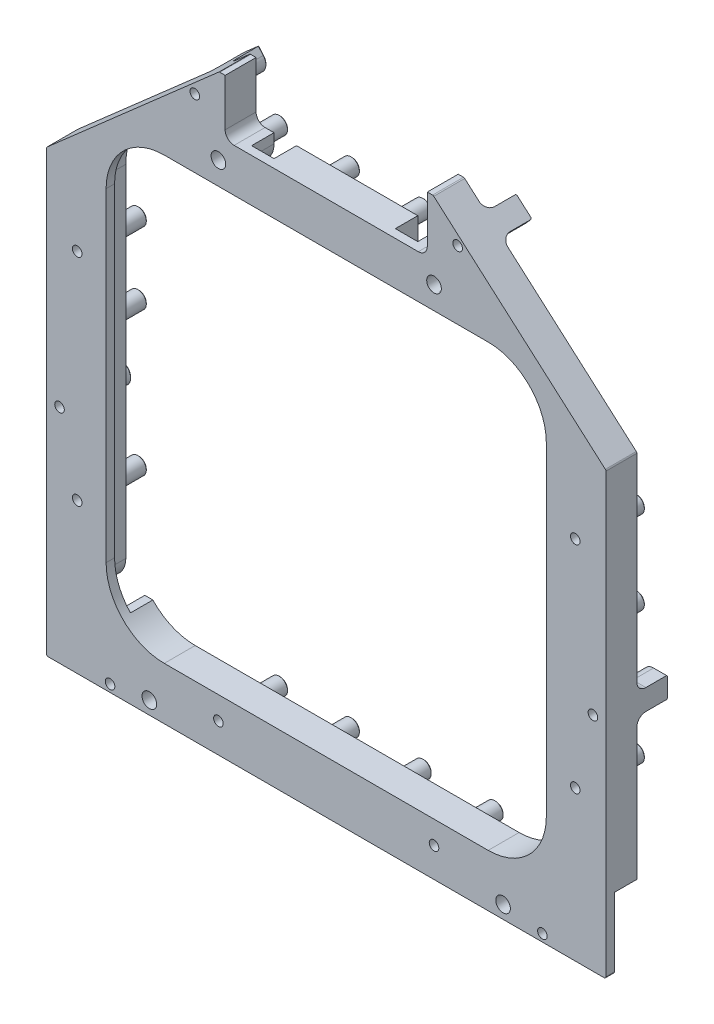
from build123d import *
from OCP.BRepFilletAPI import BRepFilletAPI_MakeChamfer

# Parameters (mm, degrees)
SKETCH1_R                      = 2.38125
BOSS_EXTRUDE1_DEPTH            = 8.6623
BOSS_EXTRUDE1_2_DEPTH          = 8.6623
BOSS_EXTRUDE1_3_DEPTH          = 8.6623
BOSS_EXTRUDE1_4_DEPTH          = 8.6623
BOSS_EXTRUDE1_5_DEPTH          = 8.6623
BOSS_EXTRUDE1_6_DEPTH          = 8.6623
BOSS_EXTRUDE1_7_DEPTH          = 8.6623
BOSS_EXTRUDE1_8_DEPTH          = 8.6623
BOSS_EXTRUDE1_9_DEPTH          = 8.6623
BOSS_EXTRUDE1_10_DEPTH         = 8.6623
BOSS_EXTRUDE1_11_DEPTH         = 8.6623
BOSS_EXTRUDE1_12_DEPTH         = 8.6623
BOSS_EXTRUDE1_13_DEPTH         = 8.6623
BOSS_EXTRUDE1_14_DEPTH         = 8.6623
BOSS_EXTRUDE1_15_DEPTH         = 8.6623
BOSS_EXTRUDE1_16_DEPTH         = 8.6623
BOSS_EXTRUDE1_17_DEPTH         = 8.6623
BOSS_EXTRUDE1_18_DEPTH         = 8.6623
BOSS_EXTRUDE1_19_DEPTH         = 8.6623
BOSS_EXTRUDE1_20_DEPTH         = 8.6623
BOSS_EXTRUDE2_START            = -17.4073
BOSS_EXTRUDE2_DEPTH            = 8.745
SKETCH6_W                      = 57.15
SKETCH6_H                      = 15.875
CUT_EXTRUDE1_DEPTH             = 189.77689907
FILLET1_R                      = 2.54
HOLE1_AT_2_COUNT               = 2
HOLE1_AT_2_PITCH               = 143.341726759
HOLE1_AT_3_COUNT               = 2
HOLE1_AT_3_PITCH               = 60.95999972
HOLE1_AT_4_COUNT               = 2
HOLE1_AT_4_PITCH               = 163.228712511
F_4_CLEARANCE_HOLE1_D          = 3.4544
HOLE2_AT_2_COUNT               = 2
HOLE2_AT_2_PITCH               = 74.316634453
HOLE2_AT_3_COUNT               = 2
HOLE2_AT_3_PITCH               = 103.157062627
HOLE2_AT_4_COUNT               = 2
HOLE2_AT_4_PITCH               = 147.81334761
HOLE2_AT_5_COUNT               = 2
HOLE2_AT_5_PITCH               = 184.754966793
HOLE2_AT_6_COUNT               = 2
HOLE2_AT_6_PITCH               = 158.272291166
HOLE2_AT_7_COUNT               = 2
HOLE2_AT_7_PITCH               = 14.486299694
HOLE2_AT_8_COUNT               = 2
HOLE2_AT_8_PITCH               = 68.849073307
HOLE2_AT_9_COUNT               = 2
HOLE2_AT_9_PITCH               = 120.885266931
HOLE2_AT_10_COUNT              = 2
HOLE2_AT_10_PITCH              = 64.409856661
HOLE2_AT_11_COUNT              = 2
HOLE2_AT_11_PITCH              = 120.791325043
HOLE2_AT_12_COUNT              = 2
HOLE2_AT_12_PITCH              = 158.288225499
HOLE2_AT_13_COUNT              = 2
HOLE2_AT_13_PITCH              = 164.709827419
HOLE2_AT_14_COUNT              = 2
HOLE2_AT_14_PITCH              = 150.329588612
F_2_CLEARANCE_HOLE1_D          = 2.7051
FILLET2_R                      = 2.54
CHAMFER1_SIZE                  = 0.254
CHAMFER1_SIZE2                 = 0.267062899
CUT_EXTRUDE2_DEPTH             = 6.35
CUT_EXTRUDE3_DEPTH             = 6.35
CUT_EXTRUDE3_DIRECTION_2_REACH = 190.777
FILLET3_R                      = 6.35
FILLET3_OF_MIRROR1_R           = 6.35


with BuildPart() as part:
    # Sketch1 → Boss-Extrude1 (new body)
    with BuildSketch(Plane.XY):
        with Locations(Location((10.159982158, 2.8e-08, 0), (0, 0, 270))):
            Circle(SKETCH1_R)
    extrude(amount=BOSS_EXTRUDE1_DEPTH)



with BuildPart() as body_2:
    # Sketch1 → Boss-Extrude1 2 (new body)
    with BuildSketch(Plane.XY):
        with Locations(Location((30.479982158, 2.8e-08, 0), (0, 0, 270))):
            Circle(SKETCH1_R)
    extrude(amount=BOSS_EXTRUDE1_2_DEPTH)


with BuildPart() as body_3:
    # Sketch1 → Boss-Extrude1 3 (new body)
    with BuildSketch(Plane.XY):
        with Locations(Location((50.799982231, 7.8e-08, 0), (0, 0, 270))):
            Circle(SKETCH1_R)
    extrude(amount=BOSS_EXTRUDE1_3_DEPTH)


with BuildPart() as body_4:
    # Sketch1 → Boss-Extrude1 4 (new body)
    with BuildSketch(Plane.XY):
        with Locations(Location((71.119982231, 7.8e-08, 0), (0, 0, 270))):
            Circle(SKETCH1_R)
    extrude(amount=BOSS_EXTRUDE1_4_DEPTH)


with BuildPart() as body_5:
    # Sketch1 → Boss-Extrude1 5 (new body)
    with BuildSketch(Plane.XY):
        with Locations(Location((111.045607114, -42.310549629, 0), (0, 0, 270))):
            Circle(SKETCH1_R)
    extrude(amount=BOSS_EXTRUDE1_5_DEPTH)


with BuildPart() as body_6:
    # Sketch1 → Boss-Extrude1 6 (new body)
    with BuildSketch(Plane.XY):
        with Locations(Location((111.045607114, -65.880549629, 0), (0, 0, 270))):
            Circle(SKETCH1_R)
    extrude(amount=BOSS_EXTRUDE1_6_DEPTH)


with BuildPart() as body_7:
    # Sketch1 → Boss-Extrude1 7 (new body)
    with BuildSketch(Plane.XY):
        with Locations(Location((111.045607114, -103.270549629, 0), (0, 0, 270))):
            Circle(SKETCH1_R)
    extrude(amount=BOSS_EXTRUDE1_7_DEPTH)


with BuildPart() as body_8:
    # Sketch1 → Boss-Extrude1 8 (new body)
    with BuildSketch(Plane.XY):
        with Locations(Location((71.119982231, -137.32609977, 0), (0, 0, 270))):
            Circle(SKETCH1_R)
    extrude(amount=BOSS_EXTRUDE1_8_DEPTH)


with BuildPart() as body_9:
    # Sketch1 → Boss-Extrude1 9 (new body)
    with BuildSketch(Plane.XY):
        with Locations(Location((50.799982231, -137.32609977, 0), (0, 0, 270))):
            Circle(SKETCH1_R)
    extrude(amount=BOSS_EXTRUDE1_9_DEPTH)


with BuildPart() as body_10:
    # Sketch1 → Boss-Extrude1 10 (new body)
    with BuildSketch(Plane.XY):
        with Locations(Location((30.479982158, -137.32609982, 0), (0, 0, 270))):
            Circle(SKETCH1_R)
    extrude(amount=BOSS_EXTRUDE1_10_DEPTH)


with BuildPart() as body_11:
    # Sketch1 → Boss-Extrude1 11 (new body)
    with BuildSketch(Plane.XY):
        with Locations(Location((10.159982158, -137.32609982, 0), (0, 0, 270))):
            Circle(SKETCH1_R)
    extrude(amount=BOSS_EXTRUDE1_11_DEPTH)


with BuildPart() as body_12:
    # Sketch1 → Boss-Extrude1 12 (new body)
    with BuildSketch(Plane.XY):
        with Locations(Location((-29.76564269, -103.270549629, 0), (0, 0, 270))):
            Circle(SKETCH1_R)
    extrude(amount=BOSS_EXTRUDE1_12_DEPTH)


with BuildPart() as body_13:
    # Sketch1 → Boss-Extrude1 13 (new body)
    with BuildSketch(Plane.XY):
        with Locations(Location((-29.76564269, -62.630549629, 0), (0, 0, 270))):
            Circle(SKETCH1_R)
    extrude(amount=BOSS_EXTRUDE1_13_DEPTH)


with BuildPart() as body_14:
    # Sketch1 → Boss-Extrude1 14 (new body)
    with BuildSketch(Plane.XY):
        with Locations(Location((-29.76564269, -42.310549629, 0), (0, 0, 270))):
            Circle(SKETCH1_R)
    extrude(amount=BOSS_EXTRUDE1_14_DEPTH)


with BuildPart() as body_15:
    # Sketch1 → Boss-Extrude1 15 (new body)
    with BuildSketch(Plane.XY):
        with BuildLine():
            Line((-23.418817868, -143.593049925), (-23.418817868, -145.688549927))
            Line((-23.418817868, -145.688549927), (-17.538717866, -145.688549927))
            Line((-17.538717866, -145.688549927), (-17.538717866, -143.593049925))
            ThreePointArc((-17.538717866, -143.593049925), (-20.478767868, -140.652999924), (-23.418817868, -143.593049925))
        make_face()
    extrude(amount=BOSS_EXTRUDE1_15_DEPTH)


with BuildPart() as body_16:
    # Sketch1 → Boss-Extrude1 16 (new body)
    with BuildSketch(Plane.XY):
        with BuildLine():
            Line((98.818682132, -143.593049842), (98.818682132, -145.688549927))
            Line((98.818682132, -145.688549927), (104.698782134, -145.688549927))
            Line((104.698782134, -145.688549927), (104.698782134, -143.593049842))
            ThreePointArc((104.698782134, -143.593049842), (101.758732132, -140.652999841), (98.818682132, -143.593049842))
        make_face()
    extrude(amount=BOSS_EXTRUDE1_16_DEPTH)


with BuildPart() as body_17:
    # Sketch1 → Boss-Extrude1 17 (new body)
    with BuildSketch(Plane.XY):
        with BuildLine():
            Line((116.04306139, -85.890599647), (119.729232093, -85.890599647))
            Line((119.729232093, -85.890599647), (119.729232093, -80.010499645))
            Line((119.729232093, -80.010499645), (116.04306139, -80.010499645))
            ThreePointArc((116.04306139, -80.010499645), (113.103011388, -82.950549647), (116.04306139, -85.890599647))
        make_face()
    extrude(amount=BOSS_EXTRUDE1_17_DEPTH)


with BuildPart() as body_18:
    # Sketch1 → Boss-Extrude1 18 (new body)
    with BuildSketch(Plane.XY):
        with BuildLine():
            Line((80.007688365, 10.915360266), (81.390206518, 12.490086848))
            Line((81.390206518, 12.490086848), (76.971428292, 16.369516574))
            Line((76.971428292, 16.369516574), (75.588910139, 14.794789992))
            ThreePointArc((75.588910139, 14.794789992), (75.858584389, 10.645686016), (80.007688365, 10.915360266))
        make_face()
    extrude(amount=BOSS_EXTRUDE1_18_DEPTH)


with BuildPart() as body_19:
    # Sketch1 → Boss-Extrude1 19 (new body)
    with BuildSketch(Plane.XY):
        with BuildLine():
            Line((5.69105391, 14.794789945), (4.308535755, 16.369516525))
            Line((4.308535755, 16.369516525), (-0.110242466, 12.490086792))
            Line((-0.110242466, 12.490086792), (1.272275689, 10.915360213))
            ThreePointArc((1.272275689, 10.915360213), (5.421379666, 10.645685968), (5.69105391, 14.794789945))
        make_face()
    extrude(amount=BOSS_EXTRUDE1_19_DEPTH)


with BuildPart() as body_20:
    # Sketch1 → Boss-Extrude1 20 (new body)
    with BuildSketch(Plane.XY):
        with BuildLine():
            Line((-34.763097208, -80.01049975), (-38.449267911, -80.01049975))
            Line((-38.449267911, -80.01049975), (-38.449267911, -85.890599752))
            Line((-38.449267911, -85.890599752), (-34.763097208, -85.890599752))
            ThreePointArc((-34.763097208, -85.890599752), (-31.823047205, -82.95054975), (-34.763097208, -80.01049975))
        make_face()
    extrude(amount=BOSS_EXTRUDE1_20_DEPTH)


with BuildPart() as part_1:
    add(part.part)

    add(body_2.part)  # Boss-Extrude2 merges body 2

    add(body_3.part)  # Boss-Extrude2 merges body 3

    add(body_4.part)  # Boss-Extrude2 merges body 4

    add(body_5.part)  # Boss-Extrude2 merges body 5

    add(body_6.part)  # Boss-Extrude2 merges body 6

    add(body_7.part)  # Boss-Extrude2 merges body 7

    add(body_8.part)  # Boss-Extrude2 merges body 8

    add(body_9.part)  # Boss-Extrude2 merges body 9

    add(body_10.part)  # Boss-Extrude2 merges body 10

    add(body_11.part)  # Boss-Extrude2 merges body 11

    add(body_12.part)  # Boss-Extrude2 merges body 12

    add(body_13.part)  # Boss-Extrude2 merges body 13

    add(body_14.part)  # Boss-Extrude2 merges body 14

    add(body_15.part)  # Boss-Extrude2 merges body 15

    add(body_16.part)  # Boss-Extrude2 merges body 16

    add(body_17.part)  # Boss-Extrude2 merges body 17

    add(body_18.part)  # Boss-Extrude2 merges body 18

    add(body_19.part)  # Boss-Extrude2 merges body 19

    add(body_20.part)  # Boss-Extrude2 merges body 20
    # Sketch3 → Boss-Extrude2 (add)
    with BuildSketch(Plane(origin=(0, 0, 0), x_dir=(-1, 0, 0), z_dir=(0, 0, -1)).offset(BOSS_EXTRUDE2_START)):
        with BuildLine():
            Line((-71.046564052, 21.571202036), (-119.556387965, -21.017595879))
            ThreePointArc((-119.556387965, -21.017595879), (-119.684008024, -21.189818788), (-119.729232049, -21.399347777))
            Line((-119.729232049, -21.399347777), (-119.729232049, -145.18054983))
            ThreePointArc((-119.729232049, -145.18054983), (-119.580442319, -145.539760015), (-119.221232133, -145.68854983))
            Line((-119.221232133, -145.68854983), (37.941267867, -145.68854983))
            ThreePointArc((37.941267867, -145.68854983), (38.300478036, -145.539760106), (38.449267867, -145.180549937))
            Line((38.449267867, -145.180549937), (38.449267867, -21.399347884))
            ThreePointArc((38.449267867, -21.399347884), (38.404043849, -21.18981893), (38.276423867, -21.017595986))
            Line((38.276423867, -21.017595986), (-10.233399988, 21.571201994))
            ThreePointArc((-10.233399988, 21.571201994), (-10.389483243, 21.664841495), (-10.568555904, 21.697450096))
            Line((-10.568555904, 21.697450096), (-24.76498202, 21.697450096))
            Line((-24.76498202, 21.697450096), (-24.76498202, 8.997450096))
            ThreePointArc((-24.76498202, 8.997450096), (-25.69491799, 6.752386066), (-27.93998202, 5.822450096))
            Line((-27.93998202, 5.822450096), (-53.33998202, 5.822450096))
            ThreePointArc((-53.33998202, 5.822450096), (-55.58504605, 6.752386066), (-56.51498202, 8.997450096))
            Line((-56.51498202, 8.997450096), (-56.51498202, 21.697450096))
            Line((-56.51498202, 21.697450096), (-70.711408136, 21.697450096))
            ThreePointArc((-70.711408136, 21.697450096), (-70.890480782, 21.664841498), (-71.046564052, 21.571202036))
        make_face()
        with BuildLine():
            Line((-102.86998205, -22.874190224), (-102.86998205, -114.451909481))
            ThreePointArc((-102.86998205, -114.451909481), (-98.054483544, -126.077551284), (-86.428841741, -130.893049852))
            Line((-86.428841741, -130.893049852), (5.148877516, -130.893049852))
            ThreePointArc((5.148877516, -130.893049852), (16.774519319, -126.077551346), (21.590017887, -114.451909543))
            Line((21.590017887, -114.451909543), (21.590017887, -22.874190286))
            ThreePointArc((21.590017887, -22.874190286), (16.774519381, -11.248548483), (5.148877578, -6.433049915))
            Line((5.148877578, -6.433049915), (-86.428841679, -6.433049915))
            ThreePointArc((-86.428841679, -6.433049915), (-98.054483482, -11.248548421), (-102.86998205, -22.874190224))
        make_face(mode=Mode.SUBTRACT)
    extrude(amount=BOSS_EXTRUDE2_DEPTH)

    # Sketch6 → Cut-Extrude1 (cut, through all)
    with BuildSketch(Plane(origin=(0, 0, 8.6623), x_dir=(-1, 0, 0), z_dir=(0, 0, -1))):
        with Locations((-40.63998205, 13.759950096)):
            Rectangle(SKETCH6_W, SKETCH6_H)
    extrude(amount=-CUT_EXTRUDE1_DEPTH, mode=Mode.SUBTRACT)

    # Fillet1
    fillet1_edges = [part_1.edges().sort_by_distance(p)[0] for p in [
        (69.21498205, 5.822450096, 13.0348),
        (12.06498205, 5.822450096, 13.0348),
    ]]
    fillet(fillet1_edges, radius=FILLET1_R)

    # Sketch7 → Hole1 (revolve, cut)
    with BuildSketch(Plane(origin=(10.159982158, 2.8e-08, 17.407299958), x_dir=(0, -1, 0), z_dir=(1, 0, 0))):
        Polygon((0, 0), (0, 3.429), (1.9431, 3.429), (2.0701, 0), align=None)
    hole1 = revolve(axis=Axis((10.159982158, 2.8e-08, -92.592700042), (0, 0, 1)), mode=Mode.SUBTRACT)

    # Hole1 at 2: Hole1 ×2
    with Locations(*[Vector(-0.13622167435737012, -0.9906783814312669, 0) * (i * HOLE1_AT_2_PITCH) for i in range(1, HOLE1_AT_2_COUNT)]):
        add(hole1, mode=Mode.SUBTRACT)

    # Hole1 at 3: Hole1 ×2
    with Locations(*[(i * HOLE1_AT_3_PITCH, 0, 0) for i in range(1, HOLE1_AT_3_COUNT)]):
        add(hole1, mode=Mode.SUBTRACT)

    # Hole1 at 4: Hole1 ×2
    with Locations(*[Vector(0.493088798568603, -0.8699789863704592, 0) * (i * HOLE1_AT_4_PITCH) for i in range(1, HOLE1_AT_4_COUNT)]):
        add(hole1, mode=Mode.SUBTRACT)

    # #4 Clearance Hole1 (through all)
    with Locations(Plane.XY.offset(17.407299958)):
        with Locations((10.159982158, 2.8e-08), (71.119981878, 2.8e-08), (-9.366267866, -142.00554983), (90.646231902, -142.00554983)):
            Hole(F_4_CLEARANCE_HOLE1_D / 2)

    # Sketch14 → Hole2 (revolve, cut)
    with BuildSketch(Plane(origin=(77.798299252, 12.855075129, 0), x_dir=(0, 1, 0), z_dir=(1, 0, 0))):
        Polygon((0, 0), (0, 2.921), (1.4986, 2.921), (1.6383, 0), align=None)
    hole2 = revolve(axis=Axis((77.798299252, 12.855075129, 110), (0, 0, -1)), mode=Mode.SUBTRACT)

    # Hole2 at 2: Hole2 ×2
    with Locations(*[(-i * HOLE2_AT_2_PITCH, 0, 0) for i in range(1, HOLE2_AT_2_COUNT)]):
        add(hole2, mode=Mode.SUBTRACT)

    # Hole2 at 3: Hole2 ×2
    with Locations(*[Vector(0.3707430316835946, -0.9287354868088422, 0) * (i * HOLE2_AT_3_PITCH) for i in range(1, HOLE2_AT_3_COUNT)]):
        add(hole2, mode=Mode.SUBTRACT)

    # Hole2 at 4: Hole2 ×2
    with Locations(*[Vector(-0.7615103661510204, -0.6481527306465189, 0) * (i * HOLE2_AT_4_PITCH) for i in range(1, HOLE2_AT_4_COUNT)]):
        add(hole2, mode=Mode.SUBTRACT)

    # Hole2 at 5: Hole2 ×2
    with Locations(*[Vector(-0.531931935718924, -0.8467871136019481, 0) * (i * HOLE2_AT_5_PITCH) for i in range(1, HOLE2_AT_5_COUNT)]):
        add(hole2, mode=Mode.SUBTRACT)

    # Hole2 at 6: Hole2 ×2
    with Locations(*[Vector(0.1513874140797138, -0.9884745069339206, 0) * (i * HOLE2_AT_6_PITCH) for i in range(1, HOLE2_AT_6_COUNT)]):
        add(hole2, mode=Mode.SUBTRACT)

    # Hole2 at 7: Hole2 ×2
    with Locations(*[Vector(-0.46100919595641693, -0.8873953579119164, 0) * (i * HOLE2_AT_7_PITCH) for i in range(1, HOLE2_AT_7_COUNT)]):
        add(hole2, mode=Mode.SUBTRACT)

    # Hole2 at 8: Hole2 ×2
    with Locations(*[Vector(-0.982414342641726, -0.1867138435462819, 0) * (i * HOLE2_AT_8_PITCH) for i in range(1, HOLE2_AT_8_COUNT)]):
        add(hole2, mode=Mode.SUBTRACT)

    # Hole2 at 9: Hole2 ×2
    with Locations(*[Vector(-0.8898019144296381, -0.45634696567124355, 0) * (i * HOLE2_AT_9_PITCH) for i in range(1, HOLE2_AT_9_COUNT)]):
        add(hole2, mode=Mode.SUBTRACT)

    # Hole2 at 10: Hole2 ×2
    with Locations(*[Vector(0.5161835406168244, -0.8564779929433559, 0) * (i * HOLE2_AT_10_PITCH) for i in range(1, HOLE2_AT_10_COUNT)]):
        add(hole2, mode=Mode.SUBTRACT)

    # Hole2 at 11: Hole2 ×2
    with Locations(*[Vector(0.2752458245651597, -0.9613738794347626, 0) * (i * HOLE2_AT_11_PITCH) for i in range(1, HOLE2_AT_11_COUNT)]):
        add(hole2, mode=Mode.SUBTRACT)

    # Hole2 at 12: Hole2 ×2
    with Locations(*[Vector(-0.6795448088624072, -0.7336340046291164, 0) * (i * HOLE2_AT_12_PITCH) for i in range(1, HOLE2_AT_12_COUNT)]):
        add(hole2, mode=Mode.SUBTRACT)

    # Hole2 at 13: Hole2 ×2
    with Locations(*[Vector(-0.41065137492894244, -0.911792437054053, 0) * (i * HOLE2_AT_13_PITCH) for i in range(1, HOLE2_AT_13_COUNT)]):
        add(hole2, mode=Mode.SUBTRACT)

    # Hole2 at 14: Hole2 ×2
    with Locations(*[Vector(-0.04442450140901661, -0.9990127445005696, 0) * (i * HOLE2_AT_14_PITCH) for i in range(1, HOLE2_AT_14_COUNT)]):
        add(hole2, mode=Mode.SUBTRACT)

    # #2 Clearance Hole1 (through all)
    with Locations(Plane(origin=(0, 0, 0), x_dir=(-1, 0, 0), z_dir=(0, 0, -1))):
        with Locations((-101.758732132, -143.593049842), (20.478767868, -143.593049925), (34.763097208, -82.95054975), (-116.04306139, -82.950549647), (-77.798299252, 12.855075129), (-3.4816648, 12.855075079), (-111.045607114, -42.310549629), (29.76564269, -42.310549629), (29.76564269, -103.270549629), (-10.159982158, -137.32609982), (-71.119982231, -137.32609977), (-111.045607114, -103.270549629), (-71.119981878, 2.8e-08), (-10.159982158, 2.8e-08)):
            Hole(F_2_CLEARANCE_HOLE1_D / 2)

    # Fillet2
    fillet2_edges = [part_1.edges().sort_by_distance(p)[0] for p in [
        (-17.538717866, -144.640799926, 8.6623),
        (-20.478767867, -140.652999924, 8.6623),
        (-36.606182559, -80.01049975, 8.6623),
        (-31.823047205, -82.950549751, 8.6623),
        (0.581016612, 11.702723503, 8.6623),
        (4.999794833, 15.582153235, 8.6623),
        (76.280169216, 15.582153283, 8.6623),
        (80.698947442, 11.702723557, 8.6623),
        (117.886146742, -80.010499645, 8.6623),
        (117.886146742, -85.890599647, 8.6623),
        (104.698782134, -144.640799885, 8.6623),
        (101.758732133, -140.652999841, 8.6623),
        (-23.418817868, -144.640799926, 8.6623),
        (-29.76564269, -100.889299629, 8.6623),
        (-36.606182559, -85.890599752, 8.6623),
        (-29.76564269, -60.249299629, 8.6623),
        (-29.76564269, -39.929299629, 8.6623),
        (5.421379666, 10.645685968, 8.6623),
        (10.159982158, 2.381250028, 8.6623),
        (30.479982158, 2.381250028, 8.6623),
        (50.799982231, 2.381250078, 8.6623),
        (71.119982231, 2.381250078, 8.6623),
        (75.858584389, 10.645686016, 8.6623),
        (111.045607114, -39.929299629, 8.6623),
        (111.045607114, -63.499299629, 8.6623),
        (113.103011388, -82.950549646, 8.6623),
        (111.045607114, -100.889299629, 8.6623),
        (98.818682132, -144.640799885, 8.6623),
        (71.119982231, -134.94484977, 8.6623),
        (50.799982231, -134.94484977, 8.6623),
        (30.479982158, -134.94484982, 8.6623),
        (10.159982158, -134.94484982, 8.6623),
    ]]
    fillet(fillet2_edges, radius=FILLET2_R)

    # Chamfer1: one chamfer whose edges measure the first distance from different faces: ONE call of the kernel's chamfer builder (chamfer() names one face for all edges)
    chamfer1_edges_1 = [part_1.edges().sort_by_distance(p)[0] for p in [
        (-23.418817868, -144.640799926, 0),
        (10.159982158, 2.381250028, 0),
        (30.479982158, 2.381250028, 0),
        (50.799982231, 2.381250078, 0),
        (71.119982231, 2.381250078, 0),
        (111.045607114, -39.929299629, 0),
        (111.045607114, -63.499299629, 0),
        (111.045607114, -100.889299629, 0),
        (71.119982231, -134.94484977, 0),
        (50.799982231, -134.94484977, 0),
        (30.479982158, -134.94484982, 0),
        (10.159982158, -134.94484982, 0),
        (-29.76564269, -100.889299629, 0),
        (-29.76564269, -60.249299629, 0),
        (-29.76564269, -39.929299629, 0),
        (-17.538717866, -144.640799926, 0),
        (-20.478767867, -140.652999924, 0),
        (101.758732133, -140.652999841, 0),
        (98.818682132, -144.640799885, 0),
        (104.698782134, -144.640799885, 0),
        (113.103011388, -82.950549646, 0),
        (117.886146742, -85.890599647, 0),
        (117.886146742, -80.010499645, 0),
        (75.858584389, 10.645686016, 0),
        (80.698947442, 11.702723557, 0),
        (76.280169216, 15.582153283, 0),
        (5.421379666, 10.645685968, 0),
        (4.999794833, 15.582153235, 0),
        (0.581016612, 11.702723503, 0),
        (-31.823047205, -82.950549751, 0),
        (-36.606182559, -80.01049975, 0),
        (-36.606182559, -85.890599752, 0),
    ]]
    chamfer1_edges_2 = [part_1.edges().sort_by_distance(p)[0] for p in [
        (71.119982231, -138.96439977, 0),
    ]]
    chamfer1_side_2 = [part_1.faces().sort_by_distance(p)[0] for p in [
        (71.119982231, -135.01220169, 0),
    ]]
    chamfer1_edges_3 = [part_1.edges().sort_by_distance(p)[0] for p in [
        (10.159982158, -138.96439982, 0),
    ]]
    chamfer1_side_3 = [part_1.faces().sort_by_distance(p)[0] for p in [
        (10.159982158, -135.012201741, 0),
    ]]
    chamfer1_edges_4 = [part_1.edges().sort_by_distance(p)[0] for p in [
        (-29.76564269, -104.908849629, 0),
    ]]
    chamfer1_side_4 = [part_1.faces().sort_by_distance(p)[0] for p in [
        (-29.76564269, -100.95665155, 0),
    ]]
    chamfer1_edges_5 = [part_1.edges().sort_by_distance(p)[0] for p in [
        (111.045607114, -104.908849629, 0),
    ]]
    chamfer1_side_5 = [part_1.faces().sort_by_distance(p)[0] for p in [
        (111.045607114, -100.95665155, 0),
    ]]
    chamfer1_edges_6 = [part_1.edges().sort_by_distance(p)[0] for p in [
        (111.045607114, -43.948849629, 0),
    ]]
    chamfer1_side_6 = [part_1.faces().sort_by_distance(p)[0] for p in [
        (111.045607114, -39.99665155, 0),
    ]]
    chamfer1_edges_7 = [part_1.edges().sort_by_distance(p)[0] for p in [
        (-29.76564269, -43.948849629, 0),
    ]]
    chamfer1_side_7 = [part_1.faces().sort_by_distance(p)[0] for p in [
        (-29.76564269, -39.99665155, 0),
    ]]
    chamfer1 = BRepFilletAPI_MakeChamfer(part_1.part.solid().wrapped)
    for e in chamfer1_edges_1:
        chamfer1.Add(CHAMFER1_SIZE, e.wrapped)
    for e in chamfer1_edges_2:
        chamfer1.Add(CHAMFER1_SIZE, CHAMFER1_SIZE2, e.wrapped, chamfer1_side_2[0].wrapped)  # the first distance lies on this face
    for e in chamfer1_edges_3:
        chamfer1.Add(CHAMFER1_SIZE, CHAMFER1_SIZE2, e.wrapped, chamfer1_side_3[0].wrapped)  # the first distance lies on this face
    for e in chamfer1_edges_4:
        chamfer1.Add(CHAMFER1_SIZE, CHAMFER1_SIZE2, e.wrapped, chamfer1_side_4[0].wrapped)  # the first distance lies on this face
    for e in chamfer1_edges_5:
        chamfer1.Add(CHAMFER1_SIZE, CHAMFER1_SIZE2, e.wrapped, chamfer1_side_5[0].wrapped)  # the first distance lies on this face
    for e in chamfer1_edges_6:
        chamfer1.Add(CHAMFER1_SIZE, CHAMFER1_SIZE2, e.wrapped, chamfer1_side_6[0].wrapped)  # the first distance lies on this face
    for e in chamfer1_edges_7:
        chamfer1.Add(CHAMFER1_SIZE, CHAMFER1_SIZE2, e.wrapped, chamfer1_side_7[0].wrapped)  # the first distance lies on this face
    add(Compound.cast(chamfer1.Shape()), mode=Mode.REPLACE)

    # Sketch18 → Cut-Extrude2 (cut)
    with BuildSketch(Plane(origin=(0, 0, 8.6623), x_dir=(-1, 0, 0), z_dir=(0, 0, -1))):
        with BuildLine():
            Line((-119.729232091, -145.18054983), (-119.729232091, -125.724149696))
            Line((-119.729232091, -125.724149696), (-100.679232091, -125.724149696))
            Line((-100.679232091, -125.724149696), (-100.679232091, -138.220375678))
            ThreePointArc((-100.679232091, -138.220375678), (-105.231140073, -139.353553279), (-107.238782133, -143.593049842))
            Line((-107.238782133, -143.593049842), (-107.238782134, -145.68854983))
            Line((-107.238782134, -145.68854983), (-119.221232133, -145.68854983))
            ThreePointArc((-119.221232133, -145.68854983), (-119.580442349, -145.539760045), (-119.729232091, -145.18054983))
        make_face()
    cut_extrude2 = extrude(amount=-CUT_EXTRUDE2_DEPTH, mode=Mode.SUBTRACT)

    # Sketch19 → Cut-Extrude3 (cut)
    with BuildSketch(Plane(origin=(0, 0, 8.6623), x_dir=(-1, 0, 0), z_dir=(0, 0, -1))):
        with BuildLine():
            Line((-86.428841679, -6.433049915), (-57.784982231, -6.433049915))
            Line((-57.784982231, -6.433049915), (-57.784982231, -3.258049915))
            Line((-57.784982231, -3.258049915), (-57.784982231, 5.822450096))
            Line((-57.784982231, 5.822450096), (-64.134982231, 5.822450096))
            Line((-64.134982231, 5.822450096), (-64.134982231, -3.258049915))
            Line((-64.134982231, -3.258049915), (-86.428841679, -3.258049884))
            ThreePointArc((-86.428841679, -3.258049884), (-100.299547534, -9.003484368), (-106.04498205, -22.874190223))
            Line((-106.04498205, -22.874190223), (-106.044982081, -114.45190948))
            Line((-106.044982081, -114.45190948), (-106.044982081, -125.724149696))
            Line((-106.044982081, -125.724149696), (-98.397454724, -125.724149696))
            ThreePointArc((-98.397454724, -125.724149696), (-101.711000313, -120.515466611), (-102.869982081, -114.451909481))
            Line((-102.869982081, -114.451909481), (-102.86998205, -22.874190224))
            ThreePointArc((-102.86998205, -22.874190224), (-98.054483482, -11.248548421), (-86.428841679, -6.433049915))
        make_face()
    cut_extrude3 = extrude(amount=-CUT_EXTRUDE3_DEPTH, mode=Mode.SUBTRACT)

    # Sketch19 → Cut-Extrude3 direction 2 (cut, up to next)
    with BuildSketch(Plane(origin=(0, 0, 8.6623), x_dir=(-1, 0, 0), z_dir=(0, 0, -1)), mode=Mode.PRIVATE) as cut_extrude3_direction_2_sk1:
        with BuildLine():
            Line((-86.428841679, -6.433049915), (-57.784982231, -6.433049915))
            Line((-57.784982231, -6.433049915), (-57.784982231, -3.258049915))
            Line((-57.784982231, -3.258049915), (-57.784982231, 5.822450096))
            Line((-57.784982231, 5.822450096), (-64.134982231, 5.822450096))
            Line((-64.134982231, 5.822450096), (-64.134982231, -3.258049915))
            Line((-64.134982231, -3.258049915), (-86.428841679, -3.258049884))
            ThreePointArc((-86.428841679, -3.258049884), (-100.299547534, -9.003484368), (-106.04498205, -22.874190223))
            Line((-106.04498205, -22.874190223), (-106.044982081, -114.45190948))
            Line((-106.044982081, -114.45190948), (-106.044982081, -125.724149696))
            Line((-106.044982081, -125.724149696), (-98.397454724, -125.724149696))
            ThreePointArc((-98.397454724, -125.724149696), (-101.711000313, -120.515466611), (-102.869982081, -114.451909481))
            Line((-102.869982081, -114.451909481), (-102.86998205, -22.874190224))
            ThreePointArc((-102.86998205, -22.874190224), (-98.054483482, -11.248548421), (-86.428841679, -6.433049915))
        make_face()
    cut_extrude3_direction_2_tool1 = extrude(cut_extrude3_direction_2_sk1.sketch, amount=CUT_EXTRUDE3_DIRECTION_2_REACH, mode=Mode.PRIVATE) & part_1.part
    cut_extrude3_direction_2 = cut_extrude3_direction_2_tool1.solids().sort_by_distance((72.106912, -5.031853, 8.6623))[0]
    add(cut_extrude3_direction_2, mode=Mode.SUBTRACT)

    # Fillet3
    fillet3_edges = [part_1.edges().sort_by_distance(p)[0] for p in [
        (64.134982231, -3.258049915, 11.8373),
        (106.044982081, -125.724149696, 11.8373),
    ]]
    fillet(fillet3_edges, radius=FILLET3_R)

    # Mirror1: Cut-Extrude2, Cut-Extrude3, Cut-Extrude3 direction 2 across plane
    add(cut_extrude2.mirror(Plane(origin=(40.639982091, 0, 0), x_dir=(0, 0, 1), z_dir=(1, 0, 0))), mode=Mode.SUBTRACT)
    add(cut_extrude3.mirror(Plane(origin=(40.639982091, 0, 0), x_dir=(0, 0, 1), z_dir=(1, 0, 0))), mode=Mode.SUBTRACT)
    add(cut_extrude3_direction_2.mirror(Plane(origin=(40.639982091, 0, 0), x_dir=(0, 0, 1), z_dir=(1, 0, 0))), mode=Mode.SUBTRACT)

    # Fillet3 of Mirror1
    fillet3_of_mirror1_edges = [part_1.edges().sort_by_distance(p)[0] for p in [
        (17.144981952, -3.258049915, 11.8373),
        (-24.765017899, -125.724149696, 11.8373),
    ]]
    fillet(fillet3_of_mirror1_edges, radius=FILLET3_OF_MIRROR1_R)


solid = part_1.part
